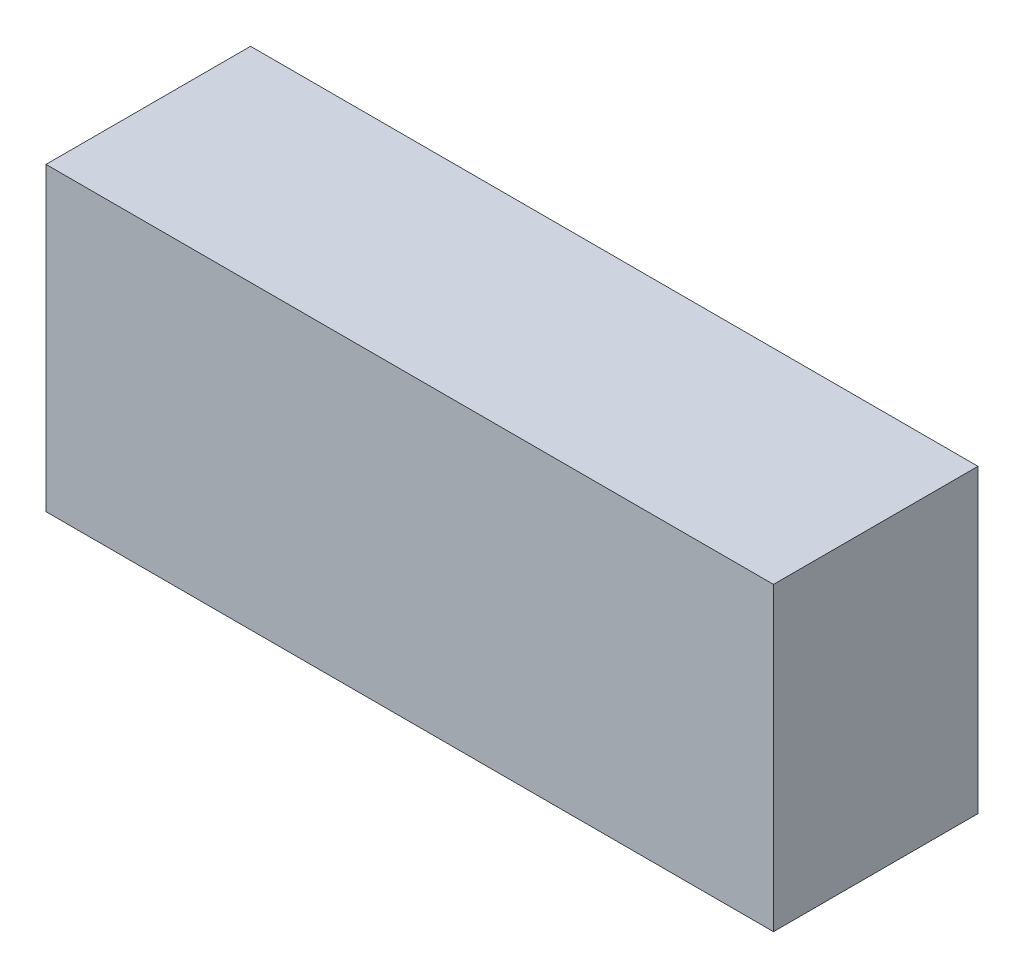
from build123d import *

# Parameters (mm, degrees)
SKETCH1_W           = 43
SKETCH1_H           = 17.78
BOSS_EXTRUDE1_DEPTH = 12.09


with BuildPart() as part:
    # Sketch1 → Boss-Extrude1 (new body)
    with BuildSketch(Plane.XY):
        Rectangle(SKETCH1_W, SKETCH1_H)
    extrude(amount=BOSS_EXTRUDE1_DEPTH)


solid = part.part
